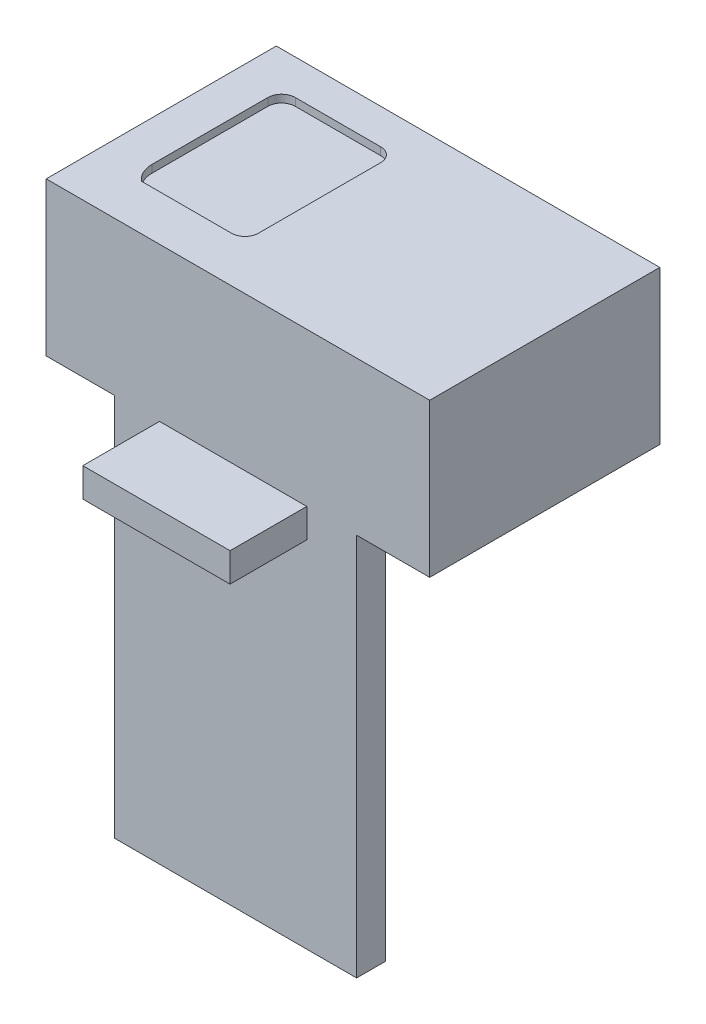
from build123d import *

# Parameters (mm, degrees)
CROQUIS1_W              = 50
CROQUIS1_H              = 30
SALIENTE_EXTRUIR1_DEPTH = 20
CORTAR_EXTRUIR1_DEPTH   = 1
CROQUIS3_W              = 31.537351035
CROQUIS3_H              = 3.738113103
SALIENTE_EXTRUIR2_DEPTH = 50
CROQUIS4_W              = 19.19980798
CROQUIS4_H              = 3.778383676
SALIENTE_EXTRUIR3_DEPTH = 10


with BuildPart() as part:
    # Croquis1 → Saliente-Extruir1 (new body)
    with BuildSketch(Plane(origin=(0, 0, 0), x_dir=(1, 0, 0), z_dir=(0, 1, 0))):
        Rectangle(CROQUIS1_W, CROQUIS1_H)
    extrude(amount=SALIENTE_EXTRUIR1_DEPTH)

    # Croquis2 → Cortar-Extruir1 (cut)
    with BuildSketch(Plane(origin=(0, 20, 0), x_dir=(1, 0, 0), z_dir=(0, 1, 0))):
        with BuildLine():
            Line((-17.950861779, 10.424113245), (-6.810393923, 10.424113245))
            ThreePointArc((-6.810393923, 10.424113245), (-5.547045664, 9.900817262), (-5.023749681, 8.637469002))
            Line((-5.023749681, 8.637469002), (-5.023749681, -7.293911131))
            ThreePointArc((-5.023749681, -7.293911131), (-5.541364738, -8.543544422), (-6.790998029, -9.061159479))
            Line((-6.790998029, -9.061159479), (-18.510223917, -9.061159479))
            ThreePointArc((-18.510223917, -9.061159479), (-19.415274859, -7.898406759), (-19.737506021, -6.460603513))
            Line((-19.737506021, -6.460603513), (-19.737506021, 8.637469002))
            ThreePointArc((-19.737506021, 8.637469002), (-19.214210038, 9.900817262), (-17.950861779, 10.424113245))
        make_face()
    extrude(amount=-CORTAR_EXTRUIR1_DEPTH, mode=Mode.SUBTRACT)

    # Croquis3 → Saliente-Extruir2 (add)
    with BuildSketch(Plane.XZ):
        with Locations((-0.297550373, 13.130943449)):
            Rectangle(CROQUIS3_W, CROQUIS3_H)
    extrude(amount=SALIENTE_EXTRUIR2_DEPTH)

    # Croquis4 → Saliente-Extruir3 (add)
    with BuildSketch(Plane.XY.offset(15)):
        with Locations((-0.62783913, -1.889191838)):
            Rectangle(CROQUIS4_W, CROQUIS4_H)
    extrude(amount=SALIENTE_EXTRUIR3_DEPTH)


solid = part.part
